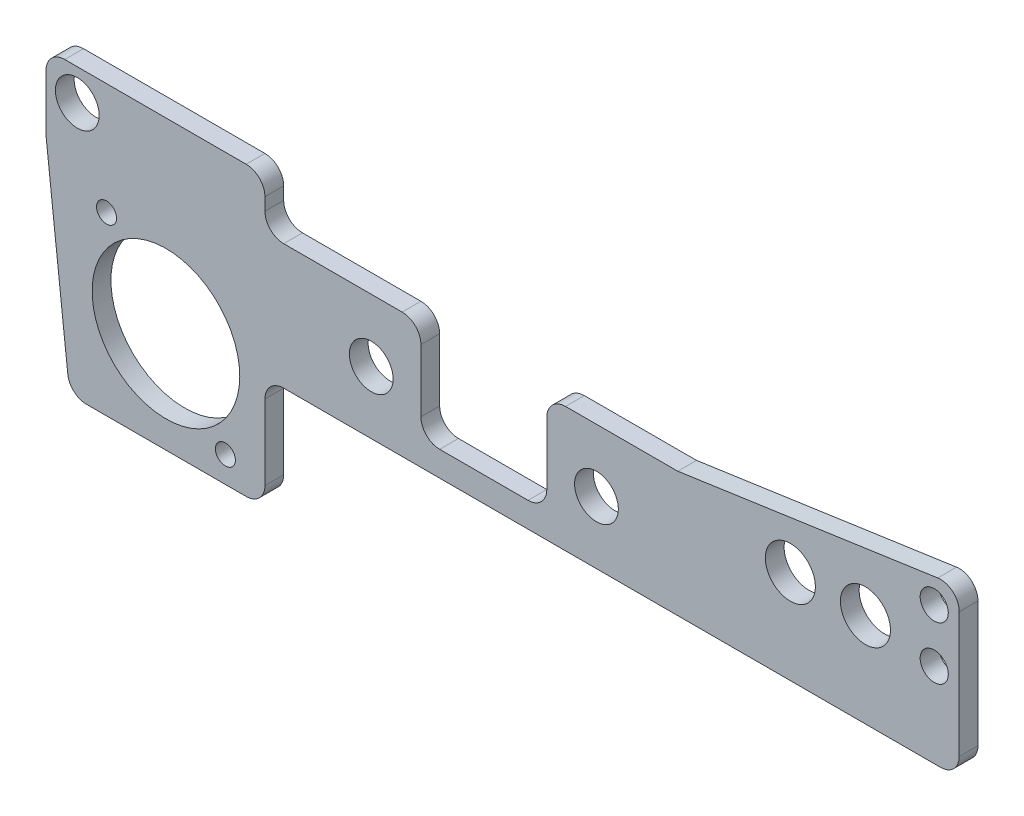
from build123d import *

# Parameters (mm, degrees)
ESQUISSE1_W              = 146
ESQUISSE1_H              = 20
BOSS_EXTRU_1_DEPTH       = 3
ESQUISSE2_R              = 3.5
ENL_V_MAT_EXTRU_3_DEPTH  = 4
ESQUISSE6_W              = 35
ESQUISSE6_H              = 3
BOSS_EXTRU_3_DEPTH       = 8
ESQUISSE8_R              = 3.5
ENL_V_MAT_EXTRU_4_DEPTH  = 8
ESQUISSE7_W              = 35
ESQUISSE7_H              = 3
BOSS_EXTRU_4_DEPTH       = 24
CONG_2_R                 = 3
ESQUISSE10_W             = 20.127249292
ESQUISSE10_H             = 16
ENL_V_MAT_EXTRU_5_DEPTH  = 24
CONG_3_R                 = 3
BOSS_EXTRU_5_DEPTH       = 3
ESQUISSE13_R             = 2.25
ENL_V_MAT_EXTRU_6_DEPTH  = 24
CONG_4_R                 = 3
ESQUISSE16_R             = 11.8
ESQUISSE16_R_2           = 1.6
ENL_V_MAT_EXTRU_7_DEPTH  = 3
ENL_V_MAT_EXTRU_11_DEPTH = 3
CONG_10_R                = 3
ESQUISSE18_R             = 4
ENL_V_MAT_EXTRU_12_DEPTH = 3


with BuildPart() as part:
    # Esquisse1 → Boss.-Extru.1 (new body)
    with BuildSketch(Plane.XY):
        with Locations((73, 10)):
            Rectangle(ESQUISSE1_W, ESQUISSE1_H)
    extrude(amount=BOSS_EXTRU_1_DEPTH)

    # Esquisse2 → Enlèv. mat.-Extru.3 (cut, through all)
    with BuildSketch(Plane.XY.offset(3)):
        with Locations((52, 10)):
            Circle(ESQUISSE2_R)
        with Locations((88, 10)):
            Circle(ESQUISSE2_R)
    extrude(amount=-ENL_V_MAT_EXTRU_3_DEPTH, mode=Mode.SUBTRACT)

    # Esquisse6 → Boss.-Extru.3 (add)
    with BuildSketch(Plane(origin=(0, 20, 0), x_dir=(1, 0, 0), z_dir=(0, 1, 0))):
        with Locations((17.5, -1.5)):
            Rectangle(ESQUISSE6_W, ESQUISSE6_H)
    extrude(amount=BOSS_EXTRU_3_DEPTH)

    # Esquisse8 → Enlèv. mat.-Extru.4 (cut)
    with BuildSketch(Plane.XY.offset(3)):
        with Locations((5, 23)):
            Circle(ESQUISSE8_R)
    extrude(amount=-ENL_V_MAT_EXTRU_4_DEPTH, mode=Mode.SUBTRACT)

    # Esquisse7 → Boss.-Extru.4 (add)
    with BuildSketch(Plane.XZ):
        with Locations((17.5, 1.5)):
            Rectangle(ESQUISSE7_W, ESQUISSE7_H)
    extrude(amount=BOSS_EXTRU_4_DEPTH)

    # Congé2
    cong_2_edges = [part.edges().sort_by_distance(p)[0] for p in [
        (35, 20, 1.5),
        (0, 28, 1.5),
        (35, 28, 1.5),
        (35, -24, 1.5),
        (0, -24, 1.5),
        (35, 0, 1.5),
        (146, 20, 1.5),
        (146, 0, 1.5),
    ]]
    fillet(cong_2_edges, radius=CONG_2_R)

    # Esquisse10 → Enlèv. mat.-Extru.5 (cut)
    with BuildSketch(Plane.XY.offset(3)):
        with Locations((70, 12)):
            Rectangle(ESQUISSE10_W, ESQUISSE10_H)
    extrude(amount=-ENL_V_MAT_EXTRU_5_DEPTH, mode=Mode.SUBTRACT)

    # Congé3
    cong_3_edges = [part.edges().sort_by_distance(p)[0] for p in [
        (80.063624646, 20, 1.5),
        (80.063624646, 4, 1.5),
        (59.936375354, 4, 1.5),
        (59.936375354, 20, 1.5),
    ]]
    fillet(cong_3_edges, radius=CONG_3_R)

    # Esquisse14 → Boss.-Extru.5 (add)
    with BuildSketch(Plane.XY.offset(3)):
        Polygon((146, 10), (146, 26.5), (101, 20), align=None)
    extrude(amount=-BOSS_EXTRU_5_DEPTH)

    # Esquisse13 → Enlèv. mat.-Extru.6 (cut)
    with BuildSketch(Plane.XY.offset(3)):
        with Locations((142, 22)):
            Circle(ESQUISSE13_R)
        with Locations((142, 13.5)):
            Circle(ESQUISSE13_R)
    extrude(amount=-ENL_V_MAT_EXTRU_6_DEPTH, mode=Mode.SUBTRACT)

    # Congé4
    cong_4_edges = [part.edges().sort_by_distance(p)[0] for p in [
        (146, 26.5, 1.5),
    ]]
    fillet(cong_4_edges, radius=CONG_4_R)

    # Esquisse16 → Enlèv. mat.-Extru.7 (cut)
    with BuildSketch(Plane.XY.offset(3)):
        with Locations((19.17587198, -1.870199746)):
            Circle(ESQUISSE16_R)
        with Locations((9.678696735, 10.161451621)):
            Circle(ESQUISSE16_R_2)
        with Locations((28.678696735, -13.838548379)):
            Circle(ESQUISSE16_R_2)
    extrude(amount=-ENL_V_MAT_EXTRU_7_DEPTH, mode=Mode.SUBTRACT)

    # Esquisse17 → Enlèv. mat.-Extru.11 (cut)
    with BuildSketch(Plane.XY.offset(3)):
        Polygon((35, -18), (3.782330551, -18), (0, 15.981074218), (0, -26.941472008), (35, -26.941472008), align=None)
    extrude(amount=-ENL_V_MAT_EXTRU_11_DEPTH, mode=Mode.SUBTRACT)

    # Congé10
    cong_10_edges = [part.edges().sort_by_distance(p)[0] for p in [
        (35, -18, 1.5),
        (0, 15.981074218, 1.5),
        (3.782330551, -18, 1.5),
    ]]
    fillet(cong_10_edges, radius=CONG_10_R)

    # Esquisse18 → Enlèv. mat.-Extru.12 (cut)
    with BuildSketch(Plane.XY.offset(3)):
        with Locations((131, 15)):
            Circle(ESQUISSE18_R)
        with Locations((119, 15)):
            Circle(ESQUISSE18_R)
    extrude(amount=-ENL_V_MAT_EXTRU_12_DEPTH, mode=Mode.SUBTRACT)


solid = part.part
